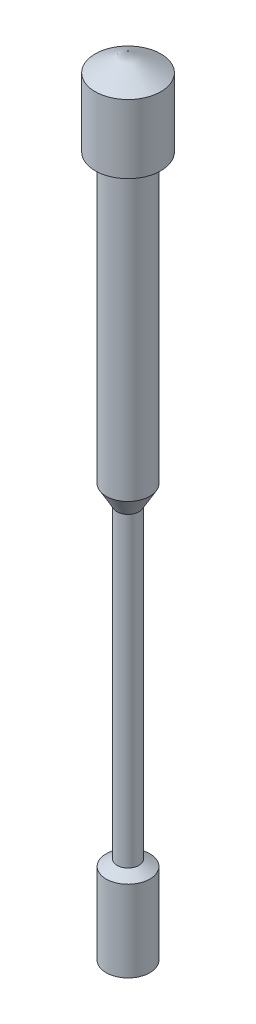
from build123d import *


with BuildPart() as part:
    # Sketch2 → Revolve1 (revolve)
    with BuildSketch(Plane.XY):
        Polygon((0, 18), (0.75, 17.566987298), (0.75, 16), (0.5, 16), (0.5, 9.433012702), (0.25, 9), (0.25, 2), (0.5, 1.855662433), (0.5, 0), (0, 0), align=None)
    revolve(axis=Axis((0, 0, 0), (0, 1, 0)))


solid = part.part
